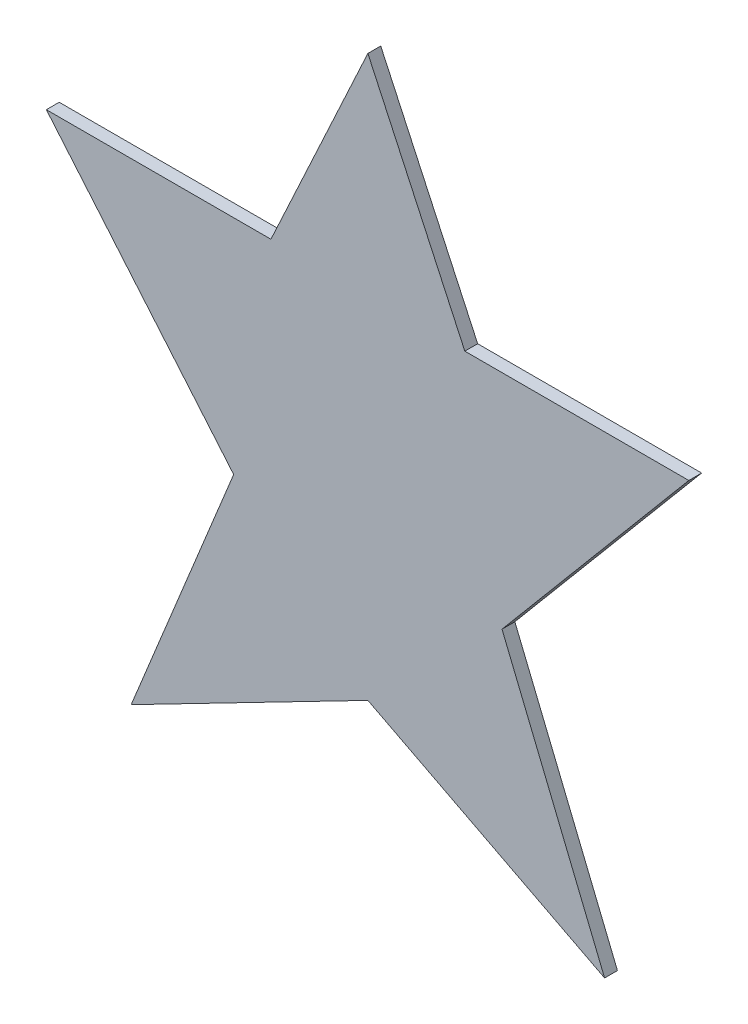
from build123d import *

# Parameters (mm, degrees)
SALIENTE_EXTRUIR1_DEPTH = 0.1


with BuildPart() as part:
    # Model → Saliente-Extruir1 (new body)
    with BuildSketch(Plane.XY):
        Polygon((9.818101322, -1.402708836), (11.562140582, -1.402708836), (10.107662294, -3.13275135), (10.906563116, -5.085641347), (9.063292553, -4.135223802), (7.220039062, -5.085674455), (8.018180558, -3.134540605), (6.559616602, -1.403579399), (8.308319708, -1.402970763), (9.063253371, 0.227541463), align=None)
    extrude(amount=SALIENTE_EXTRUIR1_DEPTH)


solid = part.part
